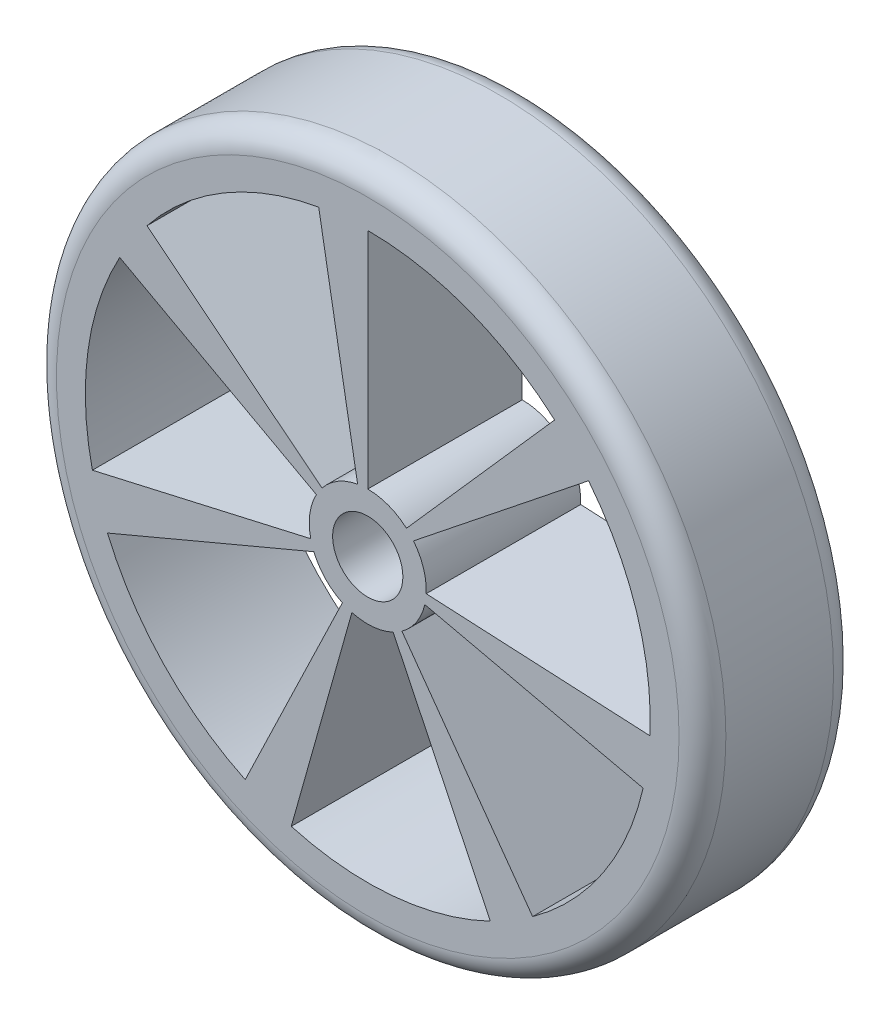
from build123d import *

# Parameters (mm, degrees)
SKETCH1_R           = 14.3
BOSS_EXTRUDE1_DEPTH = 6.6
FILLET1_R           = 1
FILLET2_R           = 1
CUT_EXTRUDE1_DEPTH  = 10
SKETCH3_R           = 1.5
CUT_EXTRUDE2_DEPTH  = 10


with BuildPart() as part:
    # Sketch1 → Boss-Extrude1 (new body)
    with BuildSketch(Plane.XY):
        Circle(SKETCH1_R)
    extrude(amount=BOSS_EXTRUDE1_DEPTH)

    # Fillet1
    fillet1_edges = [part.edges().sort_by_distance(p)[0] for p in [
        (-14.3, 0, 6.6),
    ]]
    fillet(fillet1_edges, radius=FILLET1_R)

    # Fillet2
    fillet2_edges = [part.edges().sort_by_distance(p)[0] for p in [
        (-14.3, 0, 0),
    ]]
    fillet(fillet2_edges, radius=FILLET2_R)

    # Sketch2 → Cut-Extrude1 (cut)
    with BuildSketch(Plane.XY.offset(6.6)):
        with BuildLine():
            ThreePointArc((-1.954578706, 1.558724505), (-1.276893228, 2.149312375), (-0.434120444, 2.462019383))
            Line((-0.434120444, 2.462019383), (-2.095426853, 11.883756218))
            ThreePointArc((-2.095426853, 11.883756218), (-6.163350277, 10.374371736), (-9.434424854, 7.52370276))
            Line((-9.434424854, 7.52370276), (-1.954578706, 1.558724505))
        make_face()
        with BuildLine():
            ThreePointArc((-2.43731978, -0.556302335), (-2.476529986, 0.341759021), (-2.195553933, 1.195634947))
            Line((-2.195553933, 1.195634947), (-10.597572015, 5.771130126))
            ThreePointArc((-10.597572015, 5.771130126), (-11.953796477, 1.649613694), (-11.764535365, -2.685178426))
            Line((-11.764535365, -2.685178426), (-2.43731978, -0.556302335))
        make_face()
        with BuildLine():
            ThreePointArc((-1.084709348, -2.25242217), (-1.811289152, -1.723145846), (-2.30369053, -0.971086991))
            Line((-2.30369053, -0.971086991), (-11.119529298, -4.68727466))
            ThreePointArc((-11.119529298, -4.68727466), (-8.742790117, -8.317337105), (-5.235710794, -10.87206549))
            Line((-5.235710794, -10.87206549), (-1.084709348, -2.25242217))
        make_face()
        with BuildLine():
            Line((5.235710794, -10.87206549), (1.084709348, -2.25242217))
            ThreePointArc((1.084709348, -2.25242217), (0.217889357, -2.490486745), (-0.67710117, -2.406560617))
            Line((-0.67710117, -2.406560617), (-3.268254223, -11.616066024))
            ThreePointArc((-3.268254223, -11.616066024), (1.051715522, -12.021163422), (5.235710794, -10.87206549))
        make_face()
        with BuildLine():
            Line((11.764535365, -2.685178426), (2.43731978, -0.556302335))
            ThreePointArc((2.43731978, -0.556302335), (2.082992736, -1.382440328), (1.459359181, -2.029845014))
            Line((1.459359181, -2.029845014), (7.044082942, -9.797722748))
            ThreePointArc((7.044082942, -9.797722748), (10.054257921, -6.672808494), (11.764535365, -2.685178426))
        make_face()
        with BuildLine():
            Line((9.434424854, 7.52370276), (1.954578706, 1.558724505))
            ThreePointArc((1.954578706, 1.558724505), (2.359708326, 0.825697655), (2.5, 0))
            ThreePointArc((2.5, 0), (2.499222955, -0.062326729), (2.496892303, -0.124614714))
            Line((2.496892303, -0.124614714), (12.052081979, -0.601494405))
            ThreePointArc((12.052081979, -0.601494405), (12.063331646, -0.300840709), (12.067082313, 0))
            ThreePointArc((12.067082313, 0), (11.389917841, 3.985504627), (9.434424854, 7.52370276))
        make_face()
        with BuildLine():
            Line((0, 12.067082313), (0, 2.5))
            ThreePointArc((0, 2.5), (0.884270174, 2.338389672), (1.654214594, 1.874453007))
            Line((1.654214594, 1.874453007), (7.984617468, 9.047671493))
            ThreePointArc((7.984617468, 9.047671493), (4.268224391, 11.287016262), (0, 12.067082313))
        make_face()
    extrude(amount=-CUT_EXTRUDE1_DEPTH, mode=Mode.SUBTRACT)

    # Sketch3 → Cut-Extrude2 (cut)
    with BuildSketch(Plane.XY.offset(6.6)):
        Circle(SKETCH3_R)
    extrude(amount=-CUT_EXTRUDE2_DEPTH, mode=Mode.SUBTRACT)


solid = part.part
